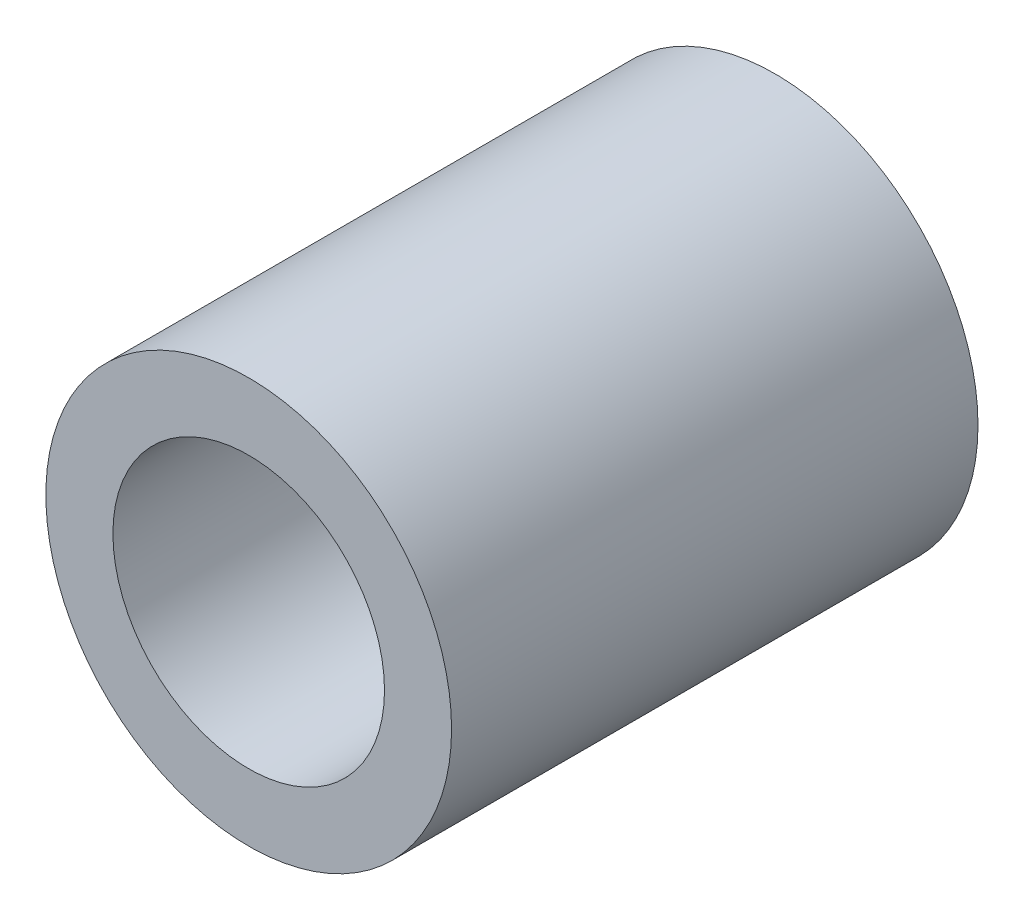
from build123d import *

# Parameters (mm, degrees)
CROQUIS1_R              = 6.05
CROQUIS1_R_2            = 4.05
SALIENTE_EXTRUIR1_DEPTH = 15.7


with BuildPart() as part:
    # Croquis1 → Saliente-Extruir1 (new body)
    with BuildSketch(Plane.XY):
        Circle(CROQUIS1_R)
        Circle(CROQUIS1_R_2, mode=Mode.SUBTRACT)
    extrude(amount=SALIENTE_EXTRUIR1_DEPTH)


solid = part.part
